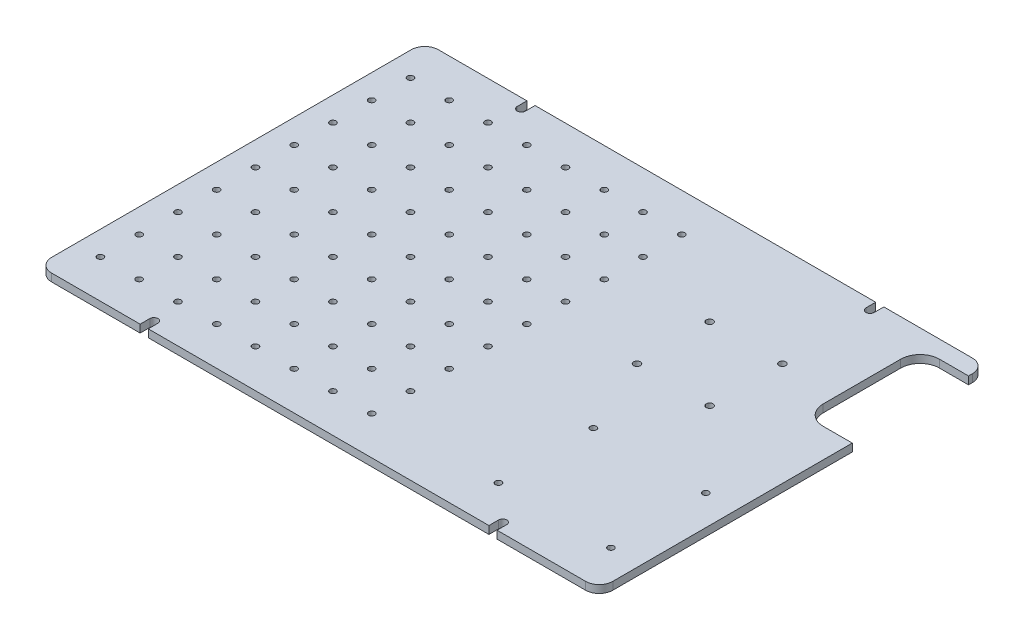
from build123d import *

# Parameters (mm, degrees)
SKETCH1_W           = 289.6
SKETCH1_H           = 199.6
BOSS_EXTRUDE1_DEPTH = 4
CUT_EXTRUDE1_DEPTH  = 5
FILLET1_R           = 7
SKETCH3_W           = 25
SKETCH3_H           = 60
CUT_EXTRUDE2_DEPTH  = 5
FILLET2_R           = 10
SKETCH4_R           = 1.6
CUT_EXTRUDE3_DEPTH  = 5
SKETCH5_R           = 1.75
CUT_EXTRUDE4_DEPTH  = 5
SKETCH6_R           = 1.59
CUT_EXTRUDE5_DEPTH  = 5


with BuildPart() as part:
    # Sketch1 → Boss-Extrude1 (new body)
    with BuildSketch(Plane(origin=(0, 0, 0), x_dir=(1, 0, 0), z_dir=(0, 1, 0))):
        Rectangle(SKETCH1_W, SKETCH1_H)
    extrude(amount=BOSS_EXTRUDE1_DEPTH)

    # Sketch2 → Cut-Extrude1 (cut, through all)
    with BuildSketch(Plane(origin=(0, 4, 0), x_dir=(1, 0, 0), z_dir=(0, 1, 0))):
        with BuildLine():
            Line((-87.9, 104.8), (-87.9, 94.8))
            ThreePointArc((-87.9, 94.8), (-90, 92.7), (-92.1, 94.8))
            Line((-92.1, 94.8), (-92.1, 104.8))
            ThreePointArc((-92.1, 104.8), (-90, 106.9), (-87.9, 104.8))
        make_face()
        with BuildLine():
            Line((92.1, 104.8), (92.1, 94.8))
            ThreePointArc((92.1, 94.8), (90, 92.7), (87.9, 94.8))
            Line((87.9, 94.8), (87.9, 104.8))
            ThreePointArc((87.9, 104.8), (90, 106.9), (92.1, 104.8))
        make_face()
    cut_extrude1 = extrude(amount=-CUT_EXTRUDE1_DEPTH, mode=Mode.SUBTRACT)

    # Mirror1: Cut-Extrude1 across plane
    add(cut_extrude1.mirror(Plane.XY), mode=Mode.SUBTRACT)

    # Fillet1
    fillet1_edges = [part.edges().sort_by_distance(p)[0] for p in [
        (144.8, 2, 99.8),
        (-144.8, 2, 99.8),
        (-144.8, 2, -99.8),
        (144.8, 2, -99.8),
    ]]
    fillet(fillet1_edges, radius=FILLET1_R)

    # Sketch3 → Cut-Extrude2 (cut, through all)
    with BuildSketch(Plane(origin=(0, 4, 0), x_dir=(1, 0, 0), z_dir=(0, 1, 0))):
        with Locations((132.3, 60.8)):
            Rectangle(SKETCH3_W, SKETCH3_H)
    extrude(amount=-CUT_EXTRUDE2_DEPTH, mode=Mode.SUBTRACT)

    # Fillet2
    fillet2_edges = [part.edges().sort_by_distance(p)[0] for p in [
        (119.8, 2, -30.8),
        (119.8, 2, -90.8),
    ]]
    fillet(fillet2_edges, radius=FILLET2_R)

    # Sketch4 → Cut-Extrude3 (cut, through all)
    with BuildSketch(Plane(origin=(0, 4, 0), x_dir=(1, 0, 0), z_dir=(0, 1, 0))):
        with Locations((129.3, -78.3)):
            Circle(SKETCH4_R)
        with Locations((71.3, -78.3)):
            Circle(SKETCH4_R)
        with Locations((129.3, -29.3)):
            Circle(SKETCH4_R)
        with Locations((71.3, -29.3)):
            Circle(SKETCH4_R)
    extrude(amount=-CUT_EXTRUDE3_DEPTH, mode=Mode.SUBTRACT)

    # Sketch5 → Cut-Extrude4 (cut, through all)
    with BuildSketch(Plane(origin=(0, 4, 0), x_dir=(1, 0, 0), z_dir=(0, 1, 0))):
        with Locations((91.3, 10.7)):
            Circle(SKETCH5_R)
        with Locations((91.3, 48.2)):
            Circle(SKETCH5_R)
        with Locations((53.8, 48.2)):
            Circle(SKETCH5_R)
        with Locations((53.8, 10.7)):
            Circle(SKETCH5_R)
    extrude(amount=-CUT_EXTRUDE4_DEPTH, mode=Mode.SUBTRACT)

    # Sketch6 → Cut-Extrude5 (cut, through all)
    with BuildSketch(Plane(origin=(0, 4, 0), x_dir=(1, 0, 0), z_dir=(0, 1, 0))):
        with Locations((7.6, 80)):
            Circle(SKETCH6_R)
        with Locations((-12.4, 80)):
            Circle(SKETCH6_R)
        with Locations((-32.4, 80)):
            Circle(SKETCH6_R)
        with Locations((-52.4, 80)):
            Circle(SKETCH6_R)
        with Locations((-72.4, 80)):
            Circle(SKETCH6_R)
        with Locations((-92.4, 80)):
            Circle(SKETCH6_R)
        with Locations((-112.4, 80)):
            Circle(SKETCH6_R)
        with Locations((-12.4, 60)):
            Circle(SKETCH6_R)
        with Locations((-32.4, 60)):
            Circle(SKETCH6_R)
        with Locations((-52.4, 60)):
            Circle(SKETCH6_R)
        with Locations((-72.4, 60)):
            Circle(SKETCH6_R)
        with Locations((-92.4, 60)):
            Circle(SKETCH6_R)
        with Locations((-112.4, 60)):
            Circle(SKETCH6_R)
        with Locations((-12.4, 40)):
            Circle(SKETCH6_R)
        with Locations((-32.4, 40)):
            Circle(SKETCH6_R)
        with Locations((-52.4, 40)):
            Circle(SKETCH6_R)
        with Locations((-72.4, 40)):
            Circle(SKETCH6_R)
        with Locations((-92.4, 40)):
            Circle(SKETCH6_R)
        with Locations((-112.4, 40)):
            Circle(SKETCH6_R)
        with Locations((-12.4, 20)):
            Circle(SKETCH6_R)
        with Locations((-32.4, 20)):
            Circle(SKETCH6_R)
        with Locations((-52.4, 20)):
            Circle(SKETCH6_R)
        with Locations((-72.4, 20)):
            Circle(SKETCH6_R)
        with Locations((-92.4, 20)):
            Circle(SKETCH6_R)
        with Locations((-112.4, 20)):
            Circle(SKETCH6_R)
        with Locations((-12.4, 0)):
            Circle(SKETCH6_R)
        with Locations((-32.4, 0)):
            Circle(SKETCH6_R)
        with Locations((-52.4, 0)):
            Circle(SKETCH6_R)
        with Locations((-72.4, 0)):
            Circle(SKETCH6_R)
        with Locations((-92.4, 0)):
            Circle(SKETCH6_R)
        with Locations((-112.4, 0)):
            Circle(SKETCH6_R)
        with Locations((-12.4, -20)):
            Circle(SKETCH6_R)
        with Locations((-32.4, -20)):
            Circle(SKETCH6_R)
        with Locations((-52.4, -20)):
            Circle(SKETCH6_R)
        with Locations((-72.4, -20)):
            Circle(SKETCH6_R)
        with Locations((-92.4, -20)):
            Circle(SKETCH6_R)
        with Locations((-112.4, -20)):
            Circle(SKETCH6_R)
        with Locations((-12.4, -40)):
            Circle(SKETCH6_R)
        with Locations((-32.4, -40)):
            Circle(SKETCH6_R)
        with Locations((-52.4, -40)):
            Circle(SKETCH6_R)
        with Locations((-72.4, -40)):
            Circle(SKETCH6_R)
        with Locations((-92.4, -40)):
            Circle(SKETCH6_R)
        with Locations((-112.4, -40)):
            Circle(SKETCH6_R)
        with Locations((-12.4, -60)):
            Circle(SKETCH6_R)
        with Locations((-32.4, -60)):
            Circle(SKETCH6_R)
        with Locations((-52.4, -60)):
            Circle(SKETCH6_R)
        with Locations((-72.4, -60)):
            Circle(SKETCH6_R)
        with Locations((-92.4, -60)):
            Circle(SKETCH6_R)
        with Locations((-112.4, -60)):
            Circle(SKETCH6_R)
        with Locations((-12.4, -80)):
            Circle(SKETCH6_R)
        with Locations((-32.4, -80)):
            Circle(SKETCH6_R)
        with Locations((-52.4, -80)):
            Circle(SKETCH6_R)
        with Locations((-72.4, -80)):
            Circle(SKETCH6_R)
        with Locations((-92.4, -80)):
            Circle(SKETCH6_R)
        with Locations((-112.4, -80)):
            Circle(SKETCH6_R)
        with Locations((7.6, 60)):
            Circle(SKETCH6_R)
        with Locations((7.6, 40)):
            Circle(SKETCH6_R)
        with Locations((7.6, 20)):
            Circle(SKETCH6_R)
        with Locations((7.6, 0)):
            Circle(SKETCH6_R)
        with Locations((7.6, -20)):
            Circle(SKETCH6_R)
        with Locations((7.6, -40)):
            Circle(SKETCH6_R)
        with Locations((7.6, -60)):
            Circle(SKETCH6_R)
        with Locations((7.6, -80)):
            Circle(SKETCH6_R)
        with Locations((-132.4, 80)):
            Circle(SKETCH6_R)
        with Locations((-132.4, 60)):
            Circle(SKETCH6_R)
        with Locations((-132.4, 40)):
            Circle(SKETCH6_R)
        with Locations((-132.4, 20)):
            Circle(SKETCH6_R)
        with Locations((-132.4, 0)):
            Circle(SKETCH6_R)
        with Locations((-132.4, -20)):
            Circle(SKETCH6_R)
        with Locations((-132.4, -40)):
            Circle(SKETCH6_R)
        with Locations((-132.4, -60)):
            Circle(SKETCH6_R)
        with Locations((-132.4, -80)):
            Circle(SKETCH6_R)
    extrude(amount=-CUT_EXTRUDE5_DEPTH, mode=Mode.SUBTRACT)


solid = part.part
